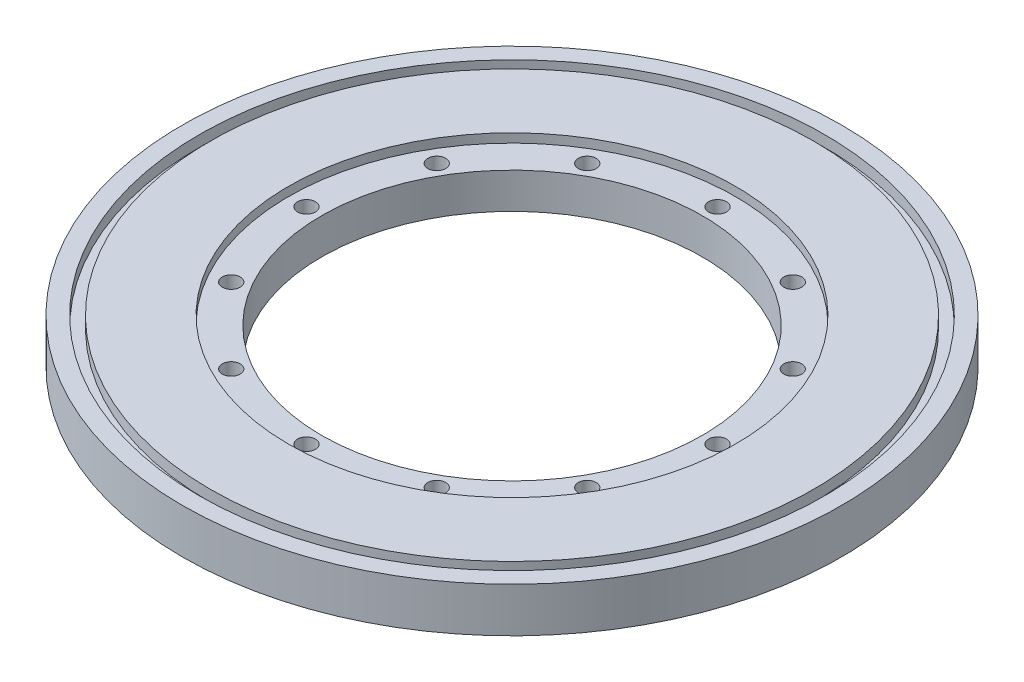
from build123d import *

# Parameters (mm, degrees)
SKETCH1_R           = 93.6625
BOSS_EXTRUDE1_DEPTH = 12.7
SKETCH2_R           = 54.102
CUT_EXTRUDE1_DEPTH  = 13.7
SKETCH3_R           = 63.5
CUT_EXTRUDE2_DEPTH  = 2.54
SKETCH4_R           = 2.54
CUT_EXTRUDE3_DEPTH  = 13.7
CIRPATTERN1_COUNT   = 12
SKETCH5_R           = 88.9
SKETCH5_R_2         = 85.725
CUT_EXTRUDE4_DEPTH  = 3.175


with BuildPart() as part:
    # Sketch1 → Boss-Extrude1 (new body)
    with BuildSketch(Plane(origin=(0, 0, 0), x_dir=(1, 0, 0), z_dir=(0, 1, 0))):
        Circle(SKETCH1_R)
    extrude(amount=BOSS_EXTRUDE1_DEPTH)

    # Sketch2 → Cut-Extrude1 (cut, through all)
    with BuildSketch(Plane(origin=(0, 12.7, 0), x_dir=(1, 0, 0), z_dir=(0, 1, 0))):
        Circle(SKETCH2_R)
    extrude(amount=-CUT_EXTRUDE1_DEPTH, mode=Mode.SUBTRACT)

    # Sketch3 → Cut-Extrude2 (cut)
    with BuildSketch(Plane(origin=(0, 12.7, 0), x_dir=(1, 0, 0), z_dir=(0, 1, 0))):
        Circle(SKETCH3_R)
    extrude(amount=-CUT_EXTRUDE2_DEPTH, mode=Mode.SUBTRACT)

    # Sketch4 → Cut-Extrude3 (cut, through all)
    with BuildSketch(Plane(origin=(0, 12.7, 0), x_dir=(1, 0, 0), z_dir=(0, 1, 0))):
        with Locations((0, 58.42)):
            Circle(SKETCH4_R)
    cut_extrude3 = extrude(amount=-CUT_EXTRUDE3_DEPTH, mode=Mode.SUBTRACT)

    # CirPattern1: Cut-Extrude3 ×12 about axis
    cirpattern1_axis = Axis((0, 0, 0), (0, 1, 0))
    for i in range(1, CIRPATTERN1_COUNT):
        add(cut_extrude3.rotate(cirpattern1_axis, i * 360 / CIRPATTERN1_COUNT), mode=Mode.SUBTRACT)

    # Sketch5 → Cut-Extrude4 (cut)
    with BuildSketch(Plane(origin=(0, 12.7, 0), x_dir=(1, 0, 0), z_dir=(0, 1, 0))):
        Circle(SKETCH5_R)
        Circle(SKETCH5_R_2, mode=Mode.SUBTRACT)
    extrude(amount=-CUT_EXTRUDE4_DEPTH, mode=Mode.SUBTRACT)


solid = part.part
